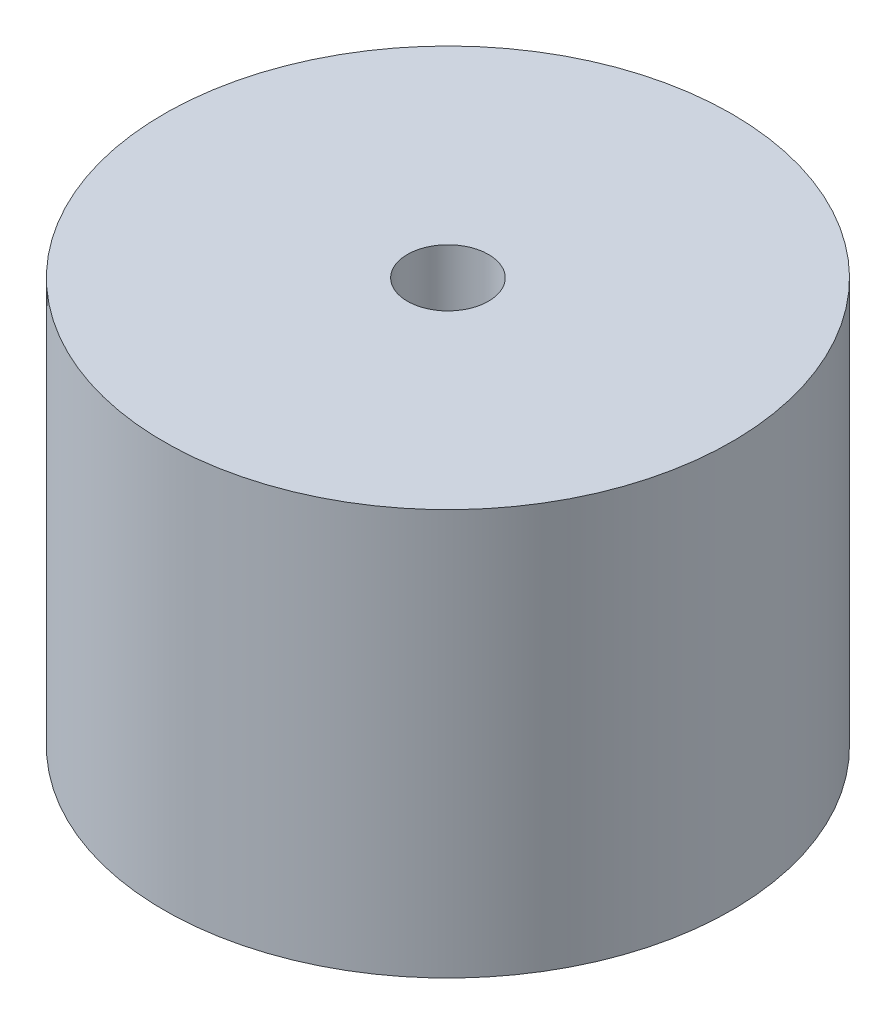
from build123d import *


with BuildPart() as part:
    # Sketch1 → Revolve1 (revolve)
    with BuildSketch(Plane.XY):
        Polygon((-41.275, 0), (-44.45, 0), (-44.45, 63.5), (-6.35, 63.5), (-6.35, 38.1), (-9.525, 38.1), (-9.525, 60.325), (-41.275, 60.325), align=None)
    revolve(axis=Axis((0, 0, 0), (0, 1, 0)))


solid = part.part
